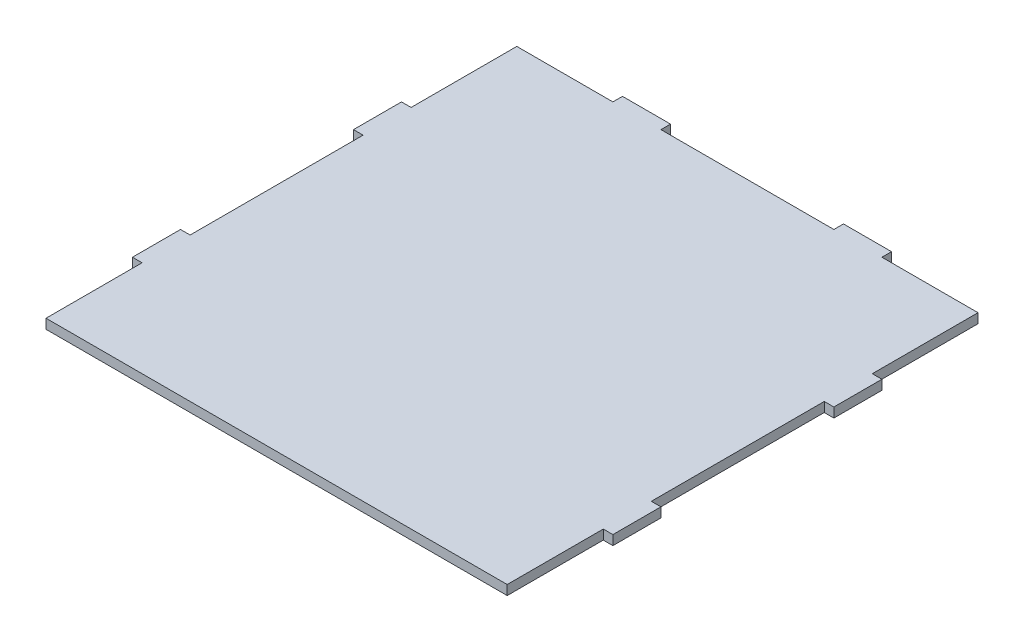
from build123d import *

# Parameters (mm, degrees)
SKETCH1_W           = 96
SKETCH1_H           = 2
BOSS_EXTRUDE1_DEPTH = 98
SKETCH2_W           = 10
SKETCH2_H           = 2
BOSS_EXTRUDE2_DEPTH = 2
SKETCH3_W           = 10
SKETCH3_H           = 2
BOSS_EXTRUDE3_DEPTH = 2
SKETCH4_W           = 10
SKETCH4_H           = 2
BOSS_EXTRUDE4_DEPTH = 2


with BuildPart() as part:
    # Sketch1 → Boss-Extrude1 (new body)
    with BuildSketch(Plane.XY):
        with Locations((0, -49)):
            Rectangle(SKETCH1_W, SKETCH1_H)
    extrude(amount=BOSS_EXTRUDE1_DEPTH)

    # Sketch2 → Boss-Extrude2 (add)
    with BuildSketch(Plane.ZY.offset(48)):
        with Locations((73, -49)):
            Rectangle(SKETCH2_W, SKETCH2_H)
    boss_extrude2 = extrude(amount=BOSS_EXTRUDE2_DEPTH)

    # Mirror1: Boss-Extrude2 across plane
    add(boss_extrude2.mirror(Plane.XY.offset(50)))

    # Sketch3 → Boss-Extrude3 (add)
    with BuildSketch(Plane(origin=(48, 0, 0), x_dir=(0, 0, -1), z_dir=(1, 0, 0))):
        with Locations((-73, -49)):
            Rectangle(SKETCH3_W, SKETCH3_H)
    boss_extrude3 = extrude(amount=BOSS_EXTRUDE3_DEPTH)

    # Mirror2: Boss-Extrude3 across plane
    add(boss_extrude3.mirror(Plane.XY.offset(50)))

    # Sketch4 → Boss-Extrude4 (add)
    with BuildSketch(Plane(origin=(0, 0, 0), x_dir=(-1, 0, 0), z_dir=(0, 0, -1))):
        with Locations((23, -49)):
            Rectangle(SKETCH4_W, SKETCH4_H)
    boss_extrude4 = extrude(amount=BOSS_EXTRUDE4_DEPTH)

    # Mirror3: Boss-Extrude4 across plane
    add(boss_extrude4.mirror(Plane(origin=(0, 0, 0), x_dir=(0, 0, 1), z_dir=(1, 0, 0))))


solid = part.part
